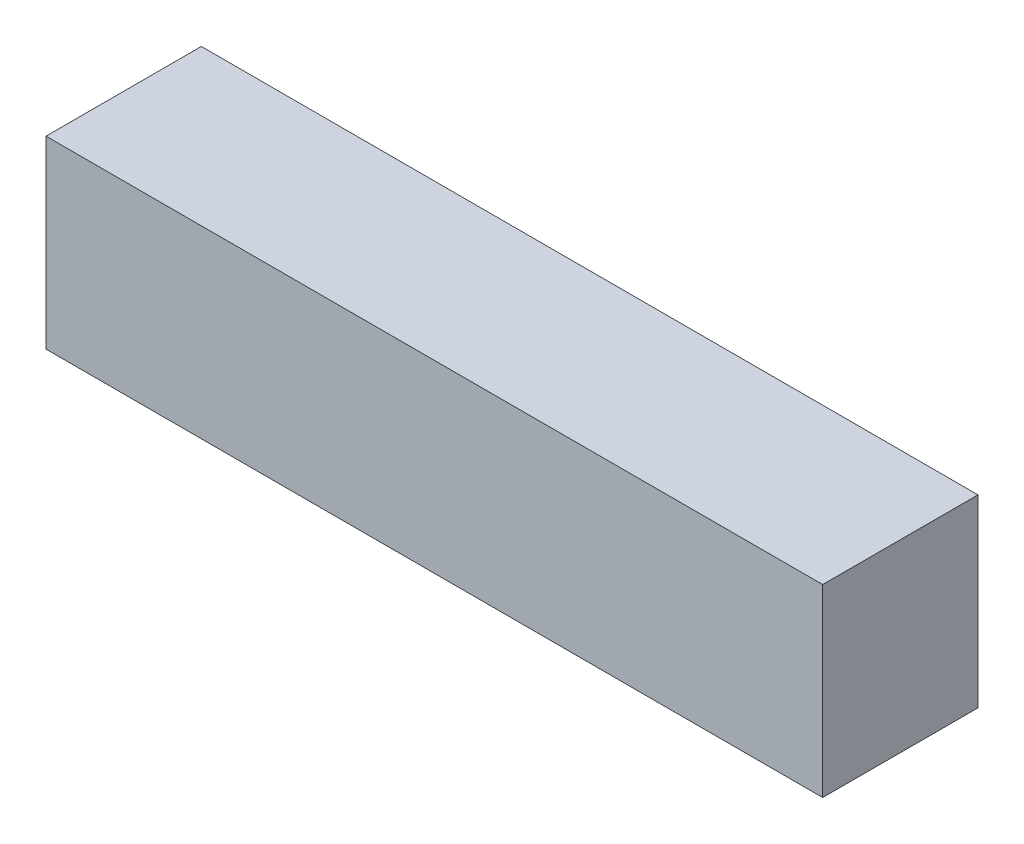
from build123d import *

# Parameters (mm, degrees)
SKETCH1_W           = 12192
SKETCH1_H           = 2438.4
BOSS_EXTRUDE1_DEPTH = 2895.6
SKETCH2_W           = 2336.8
SKETCH2_H           = 2590.8
CUT_EXTRUDE1_DEPTH  = 12039.6


with BuildPart() as part:
    # Sketch1 → Boss-Extrude1 (new body)
    with BuildSketch(Plane(origin=(0, 0, 0), x_dir=(1, 0, 0), z_dir=(0, 1, 0))):
        with Locations((6096, -1219.2)):
            Rectangle(SKETCH1_W, SKETCH1_H)
    extrude(amount=BOSS_EXTRUDE1_DEPTH)

    # Sketch2 → Cut-Extrude1 (cut)
    with BuildSketch(Plane.ZY.offset(-76.2)):
        with Locations((1219.2, 1447.8)):
            Rectangle(SKETCH2_W, SKETCH2_H)
    extrude(amount=-CUT_EXTRUDE1_DEPTH, mode=Mode.SUBTRACT)


solid = part.part
